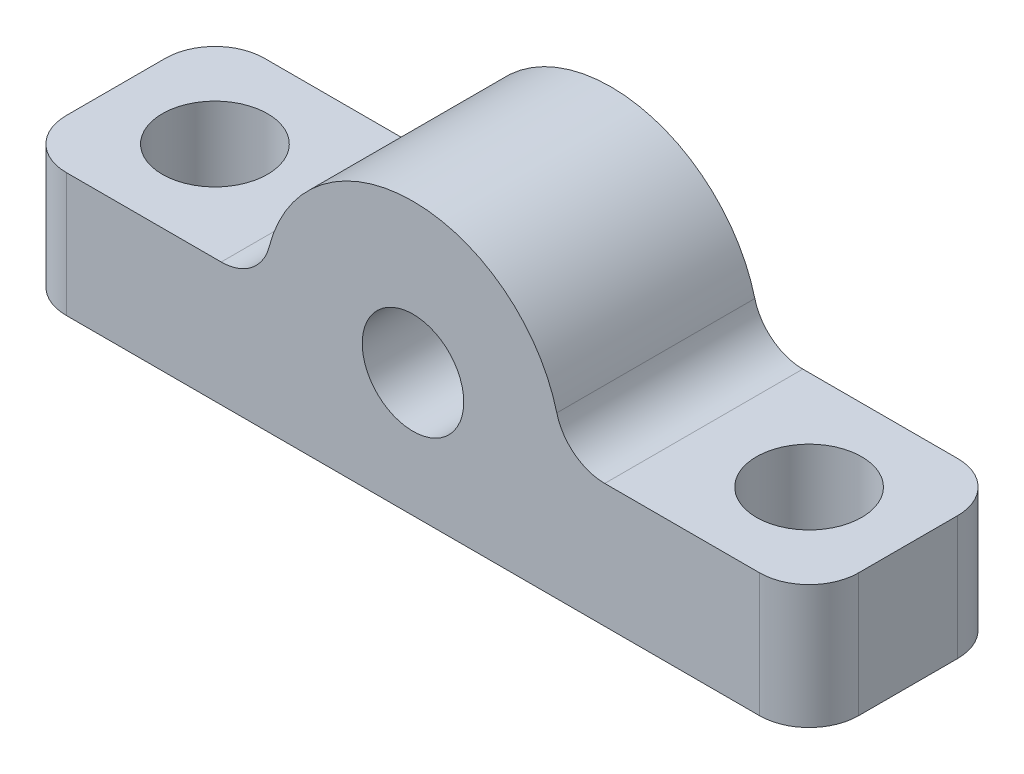
from build123d import *

# Parameters (mm, degrees)
SKETCH2_R           = 2.05
BOSS_EXTRUDE1_DEPTH = 8
SKETCH3_R           = 2.125
CUT_EXTRUDE1_DEPTH  = 8
FILLET1_R           = 2


with BuildPart() as part:
    # Sketch2 → Boss-Extrude1 (new body)
    with BuildSketch(Plane.XY):
        with BuildLine():
            Line((6, 2.5), (16, 2.5))
            Line((16, 2.5), (16, -2.5))
            Line((16, -2.5), (-16, -2.5))
            Line((-16, -2.5), (-16, 2.5))
            Line((-16, 2.5), (-6, 2.5))
            ThreePointArc((-6, 2.5), (0, 8.5), (6, 2.5))
        make_face()
        with Locations((0, 2.5)):
            Circle(SKETCH2_R, mode=Mode.SUBTRACT)
    extrude(amount=BOSS_EXTRUDE1_DEPTH)

    # Sketch3 → Cut-Extrude1 (cut)
    with BuildSketch(Plane(origin=(0, 2.5, 0), x_dir=(1, 0, 0), z_dir=(0, 1, 0))):
        with Locations((12, -4)):
            Circle(SKETCH3_R)
        with Locations((-12, -4)):
            Circle(SKETCH3_R)
    extrude(amount=-CUT_EXTRUDE1_DEPTH, mode=Mode.SUBTRACT)

    # Fillet1
    fillet1_edges = [part.edges().sort_by_distance(p)[0] for p in [
        (-6, 2.5, 4),
        (6, 2.5, 4),
        (-16, 0, 8),
        (16, 0, 8),
        (-16, 0, 0),
        (16, 0, 0),
    ]]
    fillet(fillet1_edges, radius=FILLET1_R)


solid = part.part
